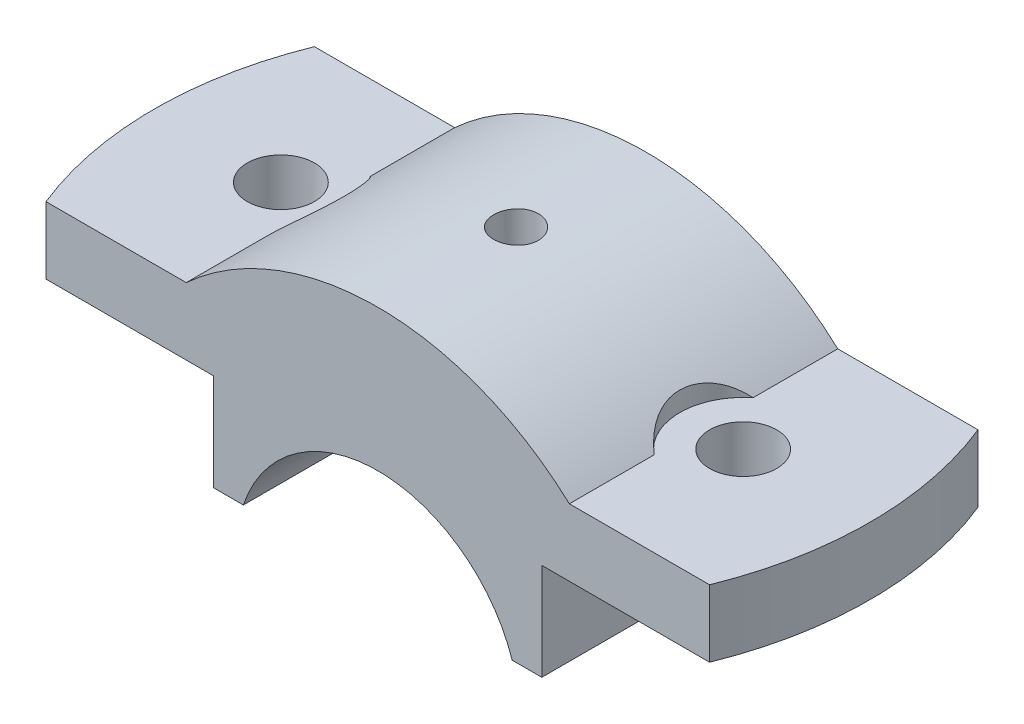
from build123d import *

# Parameters (mm, degrees)
BOSS_EXTRUDE1_DEPTH   = 18
F_8_0MM_DOWEL_HOLE1_D = 9
CUT_EXTRUDE3_DEPTH    = 35
CUT_EXTRUDE4_DEPTH    = 3


with BuildPart() as part:
    # Sketch1 → Boss-Extrude1 (new body, symmetric)
    with BuildSketch(Plane.XY):
        with BuildLine():
            Line((-18.027756377, 6), (-22, 6))
            Line((-22, 6), (-22, 19))
            Line((-22, 19), (-50, 19))
            Line((-50, 19), (-50, 28))
            Line((-50, 28), (-25.690465157, 28))
            ThreePointArc((-25.690465157, 28), (0, 38), (25.690465157, 28))
            Line((25.690465157, 28), (50, 28))
            Line((50, 28), (50, 19))
            Line((50, 19), (22, 19))
            Line((22, 19), (22, 6))
            Line((22, 6), (18.027756377, 6))
            ThreePointArc((18.027756377, 6), (0, 19), (-18.027756377, 6))
        make_face()
    extrude(amount=BOSS_EXTRUDE1_DEPTH, both=True)

    # Ø8.0mm Dowel Hole1 (through all)
    with Locations(Plane(origin=(0, 28, 0), x_dir=(1, 0, 0), z_dir=(0, 1, 0))):
        with Locations((-31, 0)):
            f_8_0mm_dowel_hole1 = Hole(F_8_0MM_DOWEL_HOLE1_D / 2)

    # Sketch6 → Cut-Extrude3 (cut)
    with BuildSketch(Plane(origin=(0, 28, 0), x_dir=(1, 0, 0), z_dir=(0, 1, 0))):
        with BuildLine():
            Line((-44.497190923, 18), (-50, 18))
            Line((-50, 18), (-50, -18))
            Line((-50, -18), (-44.497190923, -18))
            ThreePointArc((-44.497190923, -18), (-48, 0), (-44.497190923, 18))
        make_face()
        with BuildLine():
            Line((44.497190923, 18), (50, 18))
            Line((50, 18), (50, -18))
            Line((50, -18), (44.497190923, -18))
            ThreePointArc((44.497190923, -18), (48, 0), (44.497190923, 18))
        make_face()
    extrude(amount=-CUT_EXTRUDE3_DEPTH, mode=Mode.SUBTRACT)

    # Sketch9 → Cut-Extrude4 (cut)
    with BuildSketch(Plane(origin=(0, 28, 0), x_dir=(1, 0, 0), z_dir=(0, 1, 0))):
        with BuildLine():
            Line((-25.690465157, 6.637683312), (-25.690465157, -6.637683312))
            ThreePointArc((-25.690465157, -6.637683312), (-22.5, 0), (-25.690465157, 6.637683312))
        make_face()
    cut_extrude4 = extrude(amount=CUT_EXTRUDE4_DEPTH, mode=Mode.SUBTRACT)

    # Mirror3: Cut-Extrude4 across plane
    add(cut_extrude4.mirror(Plane(origin=(0, 0, 0), x_dir=(0, 0, 1), z_dir=(1, 0, 0))), mode=Mode.SUBTRACT)

    # Mirror4: Ø8.0mm Dowel Hole1 across plane
    add(f_8_0mm_dowel_hole1.mirror(Plane(origin=(0, 0, 0), x_dir=(0, 0, 1), z_dir=(1, 0, 0))), mode=Mode.SUBTRACT)

    # Sketch10 → CBORE for M5 Hex Head Bolt2 (revolve, cut)
    with BuildSketch(Plane(origin=(-0.090113613, 37.999893152, -0.630795288), x_dir=(-0.999997188, -0.002371411, 0), z_dir=(0, 0, 1))):
        Polygon((0, 0), (0, 32.113844592), (2.5, 32.113844592), (2.5, 13.300129879), (2.9995, 13), (3, 0), align=None)
    revolve(axis=Axis((-0.105172072, 44.349875297, -0.630795288), (0.002371411, -0.999997188, 0)), mode=Mode.SUBTRACT)


solid = part.part
